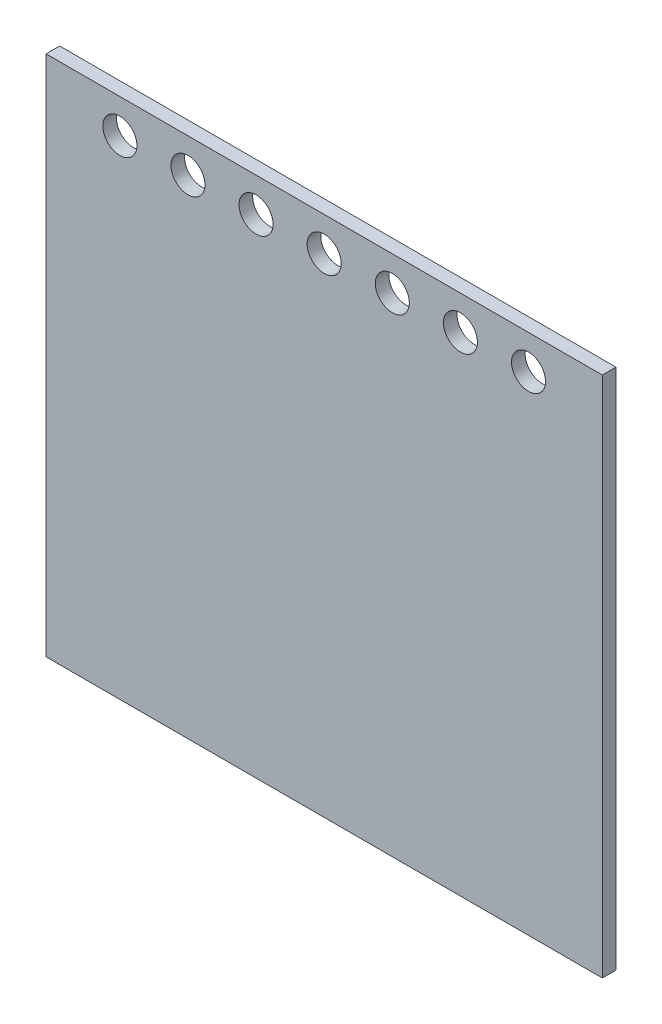
from build123d import *

# Parameters (mm, degrees)
SKETCH1_W           = 735
SKETCH1_H           = 690
SKETCH1_R           = 22.5
BOSS_EXTRUDE1_DEPTH = 18


with BuildPart() as part:
    # Sketch1 → Boss-Extrude1 (new body)
    with BuildSketch(Plane.XY):
        Rectangle(SKETCH1_W, SKETCH1_H)
        with Locations((0, 300)):
            Circle(SKETCH1_R, mode=Mode.SUBTRACT)
        with Locations((90, 300)):
            Circle(SKETCH1_R, mode=Mode.SUBTRACT)
        with Locations((180, 300)):
            Circle(SKETCH1_R, mode=Mode.SUBTRACT)
        with Locations((270, 300)):
            Circle(SKETCH1_R, mode=Mode.SUBTRACT)
        with Locations((-90, 300)):
            Circle(SKETCH1_R, mode=Mode.SUBTRACT)
        with Locations((-180, 300)):
            Circle(SKETCH1_R, mode=Mode.SUBTRACT)
        with Locations((-270, 300)):
            Circle(SKETCH1_R, mode=Mode.SUBTRACT)
    extrude(amount=BOSS_EXTRUDE1_DEPTH)


solid = part.part
